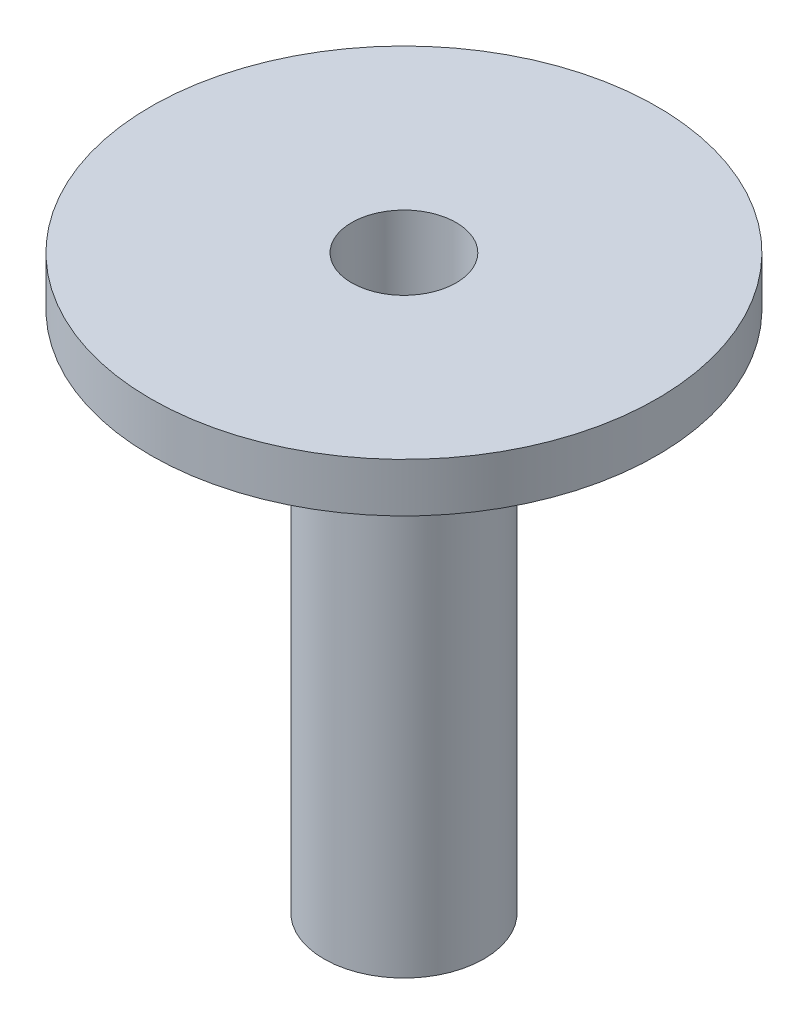
from build123d import *

# Parameters (mm, degrees)
SKETCH1_R           = 7.75
SKETCH1_R_2         = 6.75
BOSS_EXTRUDE1_DEPTH = 1.5
SKETCH2_R           = 1.6
CUT_EXTRUDE3_DEPTH  = 12.062323445
SKETCH5_R           = 2.45
SKETCH5_R_2         = 1.6
BOSS_EXTRUDE3_DEPTH = 16


with BuildPart() as part:
    # Sketch1 → Boss-Extrude1 (new body)
    with BuildSketch(Plane(origin=(0, 0, 0), x_dir=(1, 0, 0), z_dir=(0, 1, 0))):
        with Locations(Location((0, 0, 0), (0, 0, 270))):
            Circle(SKETCH1_R)
        Circle(SKETCH1_R_2, mode=Mode.SUBTRACT)
        Circle(SKETCH1_R_2)
    extrude(amount=BOSS_EXTRUDE1_DEPTH)

    # Sketch2 → Cut-Extrude3 (cut, through all)
    with BuildSketch(Plane(origin=(0, 1.5, 0), x_dir=(1, 0, 0), z_dir=(0, 1, 0))):
        with Locations(Location((0, 0, 0), (0, 0, 270))):
            Circle(SKETCH2_R)
    extrude(amount=-CUT_EXTRUDE3_DEPTH, mode=Mode.SUBTRACT)

    # Sketch5 → Boss-Extrude3 (add)
    with BuildSketch(Plane(origin=(0, 0, 0), x_dir=(-1, 0, 0), z_dir=(0, -1, 0))):
        with Locations(Location((0, 0, 0), (0, 0, 270))):
            Circle(SKETCH5_R)
        with Locations(Location((0, 0, 0), (0, 0, 270))):
            Circle(SKETCH5_R_2, mode=Mode.SUBTRACT)
    extrude(amount=BOSS_EXTRUDE3_DEPTH)


solid = part.part
